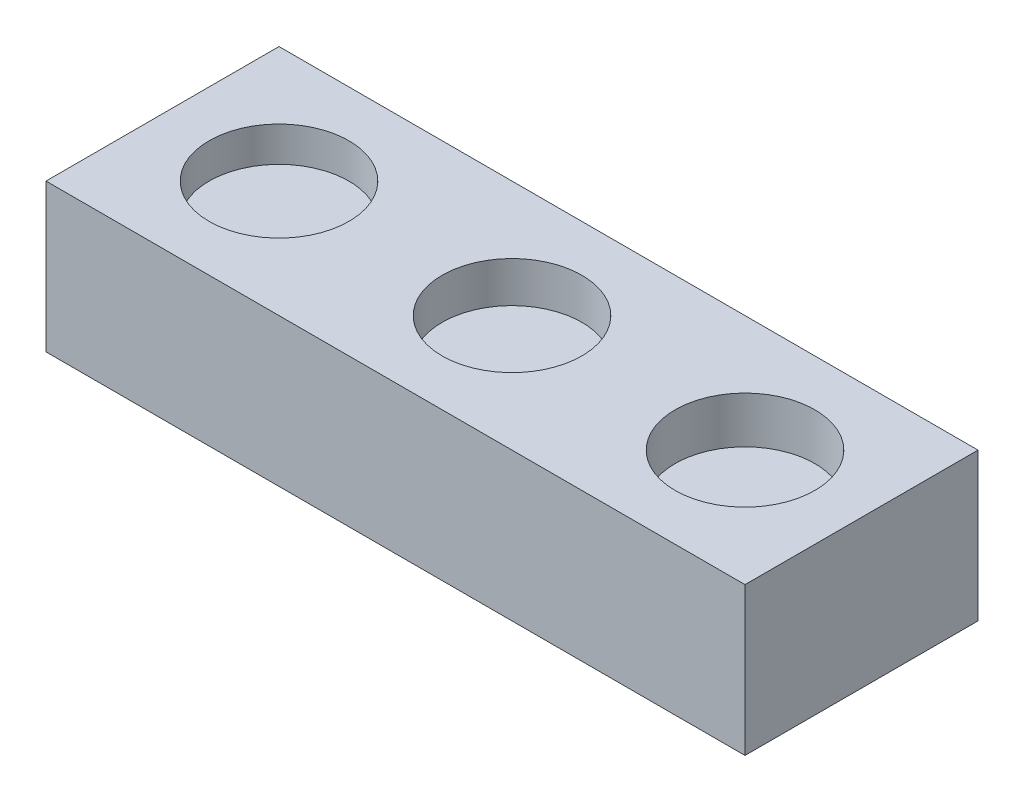
from build123d import *

# Parameters (mm, degrees)
SKETCH1_W           = 30
SKETCH1_H           = 10
BOSS_EXTRUDE1_DEPTH = 6.35
SKETCH2_R           = 3
CUT_EXTRUDE1_DEPTH  = 1.75
SKETCH4_R           = 3
CUT_EXTRUDE2_DEPTH  = 1.5
SKETCH5_R           = 3
CUT_EXTRUDE3_DEPTH  = 2


with BuildPart() as part:
    # Sketch1 → Boss-Extrude1 (new body)
    with BuildSketch(Plane(origin=(0, 0, 0), x_dir=(1, 0, 0), z_dir=(0, 1, 0))):
        with Locations((15, 5)):
            Rectangle(SKETCH1_W, SKETCH1_H)
    extrude(amount=BOSS_EXTRUDE1_DEPTH)

    # Sketch2 → Cut-Extrude1 (cut)
    with BuildSketch(Plane(origin=(0, 6.35, 0), x_dir=(1, 0, 0), z_dir=(0, 1, 0))):
        with Locations((15, 5)):
            Circle(SKETCH2_R)
    extrude(amount=-CUT_EXTRUDE1_DEPTH, mode=Mode.SUBTRACT)

    # Sketch4 → Cut-Extrude2 (cut)
    with BuildSketch(Plane(origin=(0, 6.35, 0), x_dir=(1, 0, 0), z_dir=(0, 1, 0))):
        with Locations((5, 5)):
            Circle(SKETCH4_R)
    extrude(amount=-CUT_EXTRUDE2_DEPTH, mode=Mode.SUBTRACT)

    # Sketch5 → Cut-Extrude3 (cut)
    with BuildSketch(Plane(origin=(0, 6.35, 0), x_dir=(1, 0, 0), z_dir=(0, 1, 0))):
        with Locations((25, 5)):
            Circle(SKETCH5_R)
    extrude(amount=-CUT_EXTRUDE3_DEPTH, mode=Mode.SUBTRACT)


solid = part.part
